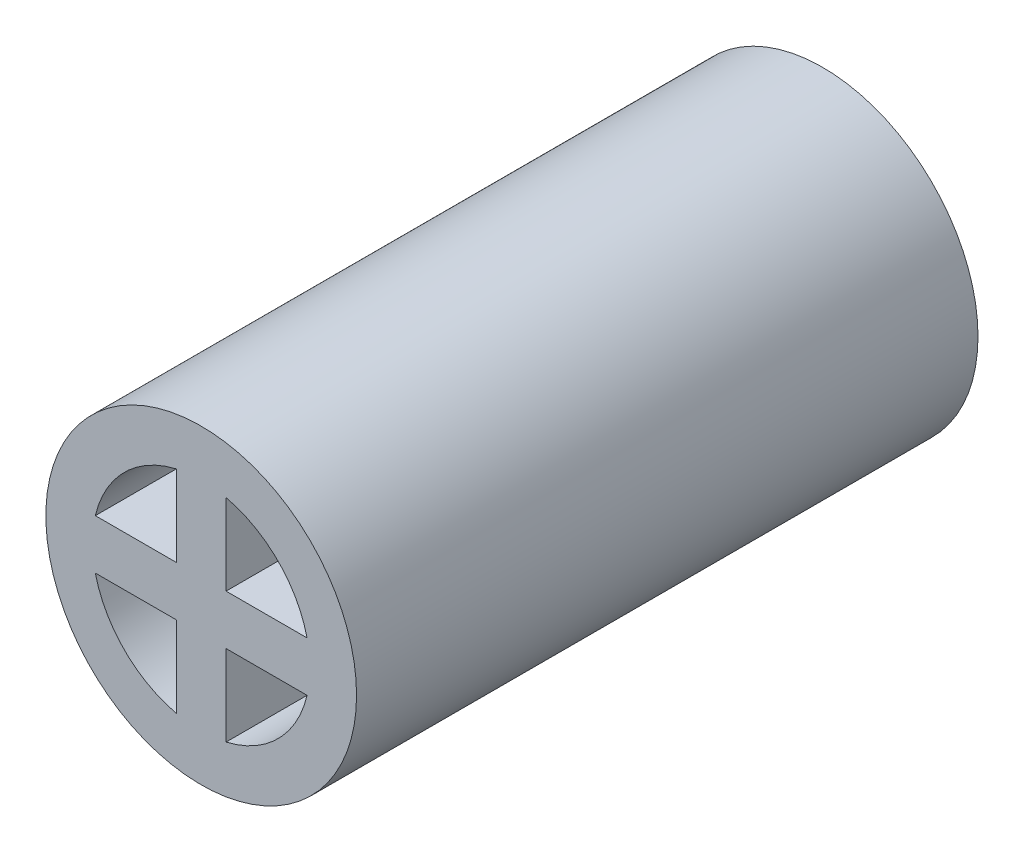
from build123d import *

# Parameters (mm, degrees)
SKETCH1_R           = 12.5
SKETCH1_R_2         = 8.75
BOSS_EXTRUDE1_DEPTH = 50
BOSS_EXTRUDE2_DEPTH = 50


with BuildPart() as part:
    # Sketch1 → Boss-Extrude1 (new body)
    with BuildSketch(Plane.XY):
        Circle(SKETCH1_R)
        Circle(SKETCH1_R_2, mode=Mode.SUBTRACT)
    extrude(amount=BOSS_EXTRUDE1_DEPTH)

    # Sketch2 → Boss-Extrude2 (add)
    with BuildSketch(Plane.XY):
        with BuildLine():
            Line((-2, -8.518362519), (-2, -2))
            Line((-2, -2), (-8.518362519, -2))
            ThreePointArc((-8.518362519, -2), (-8.75, 0), (-8.518362519, 2))
            Line((-8.518362519, 2), (-2, 2))
            Line((-2, 2), (-2, 8.518362519))
            ThreePointArc((-2, 8.518362519), (0, 8.75), (2, 8.518362519))
            Line((2, 8.518362519), (2, 2))
            Line((2, 2), (8.518362519, 2))
            ThreePointArc((8.518362519, 2), (8.75, 0), (8.518362519, -2))
            Line((8.518362519, -2), (2, -2))
            Line((2, -2), (2, -8.518362519))
            ThreePointArc((2, -8.518362519), (0, -8.75), (-2, -8.518362519))
        make_face()
    extrude(amount=BOSS_EXTRUDE2_DEPTH)


solid = part.part
